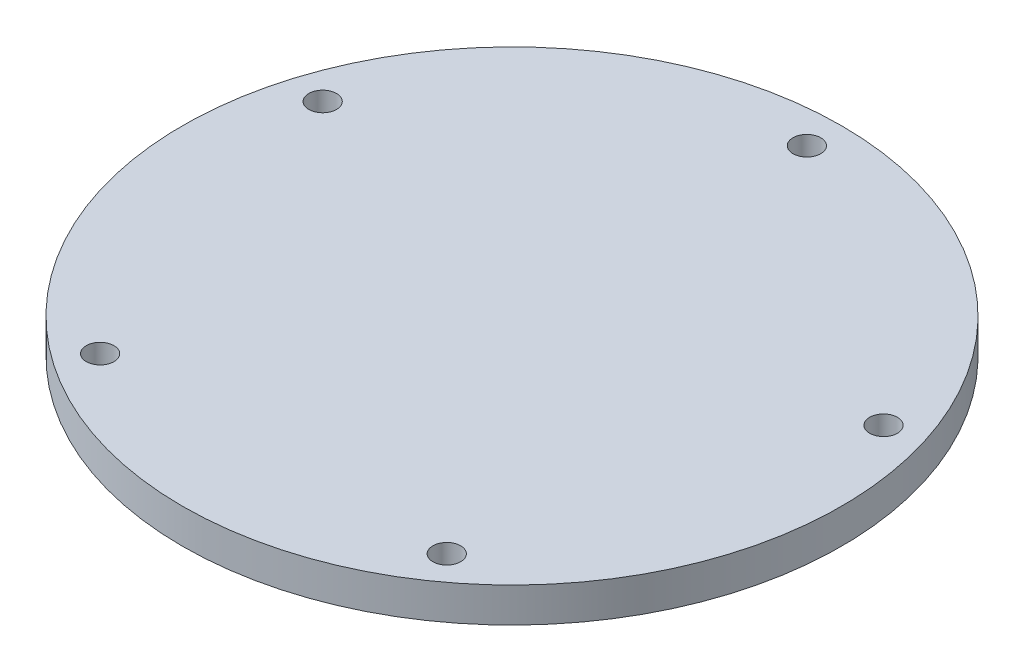
from build123d import *

# Parameters (mm, degrees)
SKETCH1_R           = 47.5
SKETCH1_R_2         = 2
BOSS_EXTRUDE1_DEPTH = 5


with BuildPart() as part:
    # Sketch1 → Boss-Extrude1 (new body)
    with BuildSketch(Plane(origin=(0, 0, 0), x_dir=(1, 0, 0), z_dir=(0, 1, 0))):
        Circle(SKETCH1_R)
        with Locations((0, 42.5)):
            Circle(SKETCH1_R_2, mode=Mode.SUBTRACT)
        with Locations((40.419901943, 13.133222261)):
            Circle(SKETCH1_R_2, mode=Mode.SUBTRACT)
        with Locations((24.980873222, -34.383222261)):
            Circle(SKETCH1_R_2, mode=Mode.SUBTRACT)
        with Locations((-24.980873222, -34.383222261)):
            Circle(SKETCH1_R_2, mode=Mode.SUBTRACT)
        with Locations((-40.419901943, 13.133222261)):
            Circle(SKETCH1_R_2, mode=Mode.SUBTRACT)
    extrude(amount=BOSS_EXTRUDE1_DEPTH)


solid = part.part
